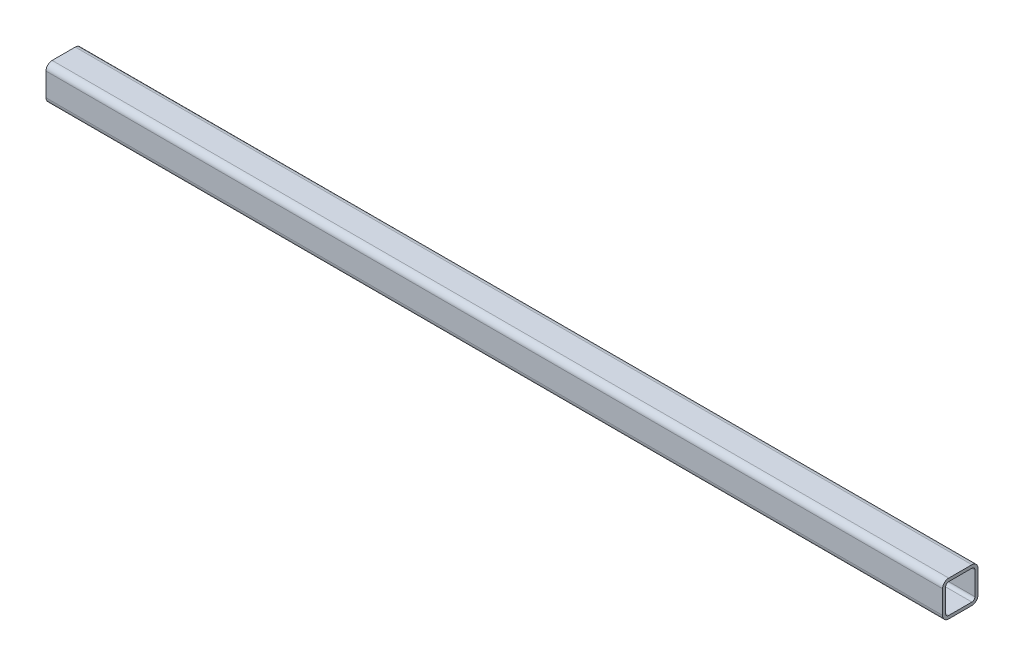
from build123d import *

# Parameters (mm, degrees)
SQUARE_TUBE_CONFIGURED_30_X_30_X_2_6_1_DEPTH = 760


with BuildPart() as part:
    # Sketch13 → Square tube - configured 30 X 30 X 2.6(1) (new body)
    with BuildSketch(Plane.YZ.offset(-380)):
        with BuildLine():
            Line((-9.8, -15), (9.8, -15))
            ThreePointArc((9.8, -15), (13.476955262, -13.476955262), (15, -9.8))
            Line((15, -9.8), (15, 9.8))
            ThreePointArc((15, 9.8), (13.476955262, 13.476955262), (9.8, 15))
            Line((9.8, 15), (-9.8, 15))
            ThreePointArc((-9.8, 15), (-13.476955262, 13.476955262), (-15, 9.8))
            Line((-15, 9.8), (-15, -9.8))
            ThreePointArc((-15, -9.8), (-13.476955262, -13.476955262), (-9.8, -15))
        make_face()
        with BuildLine():
            Line((-9.8, -12.4), (9.8, -12.4))
            ThreePointArc((9.8, -12.4), (11.638477631, -11.638477631), (12.4, -9.8))
            Line((12.4, -9.8), (12.4, 9.8))
            ThreePointArc((12.4, 9.8), (11.638477631, 11.638477631), (9.8, 12.4))
            Line((9.8, 12.4), (-9.8, 12.4))
            ThreePointArc((-9.8, 12.4), (-11.638477631, 11.638477631), (-12.4, 9.8))
            Line((-12.4, 9.8), (-12.4, -9.8))
            ThreePointArc((-12.4, -9.8), (-11.638477631, -11.638477631), (-9.8, -12.4))
        make_face(mode=Mode.SUBTRACT)
    extrude(amount=SQUARE_TUBE_CONFIGURED_30_X_30_X_2_6_1_DEPTH)


solid = part.part
